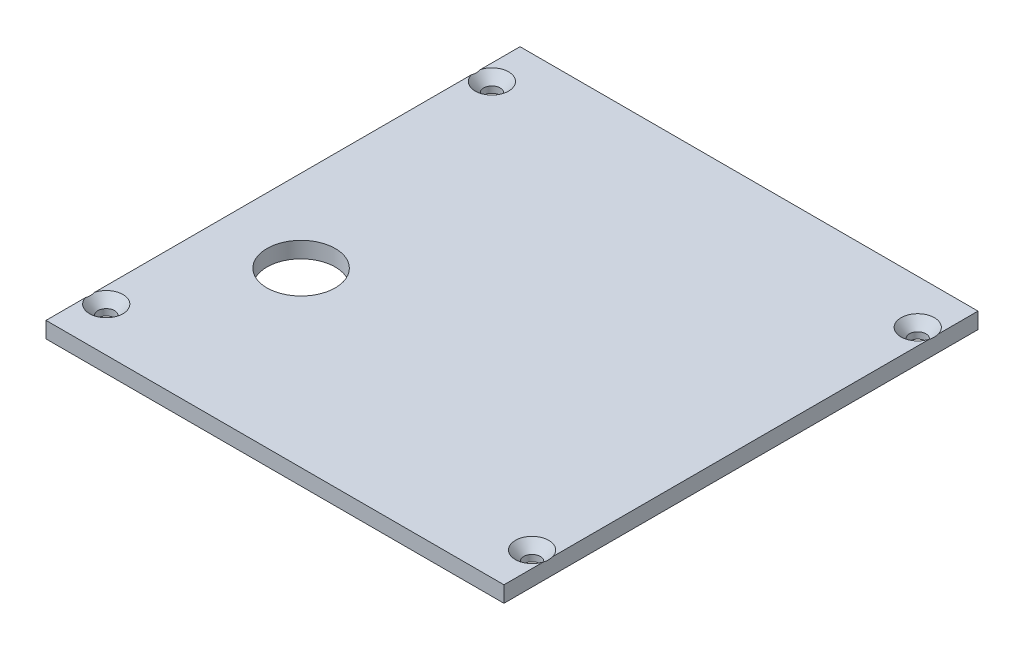
from build123d import *

# Parameters (mm, degrees)
SKETCH1_W                                     = 90.4875
SKETCH1_H                                     = 93.6625
BOSS_EXTRUDE1_DEPTH                           = 3.175
CSK_FOR_4_FLAT_HEAD_MACHINE_SCREW1_AT_2_COUNT = 2
CSK_FOR_4_FLAT_HEAD_MACHINE_SCREW1_AT_2_PITCH = 113.514575744
CSK_FOR_4_FLAT_HEAD_MACHINE_SCREW1_AT_3_COUNT = 2
CSK_FOR_4_FLAT_HEAD_MACHINE_SCREW1_AT_3_PITCH = 84.1375
CSK_FOR_4_FLAT_HEAD_MACHINE_SCREW1_AT_4_COUNT = 2
CSK_FOR_4_FLAT_HEAD_MACHINE_SCREW1_AT_4_PITCH = 76.2
SKETCH4_R                                     = 6.746875
CUT_EXTRUDE1_DEPTH                            = 4.175


with BuildPart() as part:
    # Sketch1 → Boss-Extrude1 (new body)
    with BuildSketch(Plane(origin=(0, 0, 0), x_dir=(1, 0, 0), z_dir=(0, 1, 0))):
        Rectangle(SKETCH1_W, SKETCH1_H)
    extrude(amount=BOSS_EXTRUDE1_DEPTH)

    # Sketch3 → CSK for #4 Flat Head Machine Screw1 (revolve, cut)
    with BuildSketch(Plane(origin=(42.06875, 3.175, 38.1), x_dir=(0, 0, 1), z_dir=(1, 0, 0))):
        Polygon((0, 0), (0, 3.175), (1.63195, 3.175), (1.63195, 1.917827142), (3.2990917, 0), align=None)
    csk_for_4_flat_head_machine_screw1 = revolve(axis=Axis((42.06875, 9.525, 38.1), (0, -1, 0)), mode=Mode.SUBTRACT)

    # CSK for #4 Flat Head Machine Screw1 at 2: CSK for #4 Flat Head Machine Screw1 ×2
    with Locations(*[Vector(-0.741204374, 0, -0.671279433) * (i * CSK_FOR_4_FLAT_HEAD_MACHINE_SCREW1_AT_2_PITCH) for i in range(1, CSK_FOR_4_FLAT_HEAD_MACHINE_SCREW1_AT_2_COUNT)]):
        add(csk_for_4_flat_head_machine_screw1, mode=Mode.SUBTRACT)

    # CSK for #4 Flat Head Machine Screw1 at 3: CSK for #4 Flat Head Machine Screw1 ×2
    with Locations(*[(-i * CSK_FOR_4_FLAT_HEAD_MACHINE_SCREW1_AT_3_PITCH, 0, 0) for i in range(1, CSK_FOR_4_FLAT_HEAD_MACHINE_SCREW1_AT_3_COUNT)]):
        add(csk_for_4_flat_head_machine_screw1, mode=Mode.SUBTRACT)

    # CSK for #4 Flat Head Machine Screw1 at 4: CSK for #4 Flat Head Machine Screw1 ×2
    with Locations(*[(0, 0, -i * CSK_FOR_4_FLAT_HEAD_MACHINE_SCREW1_AT_4_PITCH) for i in range(1, CSK_FOR_4_FLAT_HEAD_MACHINE_SCREW1_AT_4_COUNT)]):
        add(csk_for_4_flat_head_machine_screw1, mode=Mode.SUBTRACT)

    # Sketch4 → Cut-Extrude1 (cut, through all)
    with BuildSketch(Plane(origin=(0, 3.175, 0), x_dir=(1, 0, 0), z_dir=(0, 1, 0))):
        with Locations(Location((-28.971875, -12.7, 0), (0, 0, 270))):  # turned: the seam where the file's is
            Circle(SKETCH4_R)
    extrude(amount=-CUT_EXTRUDE1_DEPTH, mode=Mode.SUBTRACT)


solid = part.part
